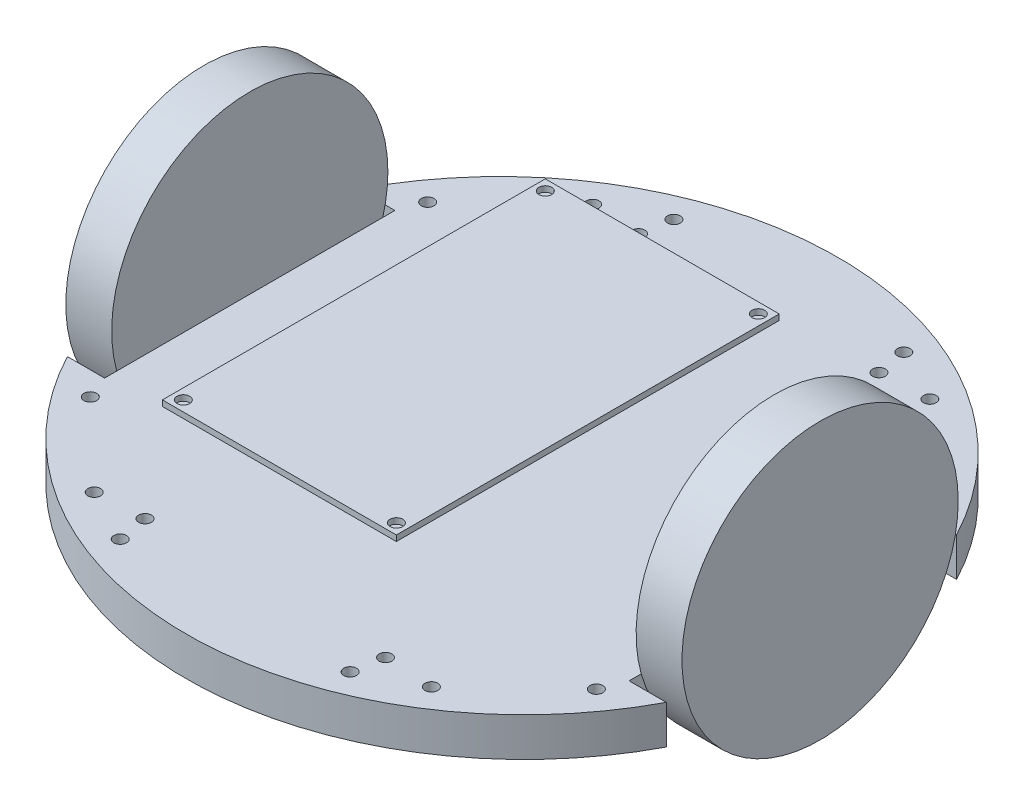
from build123d import *

# Parameters (mm, degrees)
BOSS_EXTRUDE1_DEPTH     = 9.652
SKETCH4_R               = 1.5875
CUT_EXTRUDE1_DEPTH      = 9.652
MIRROR3_COPY_1_SKETCH_R = 1.5875
MIRROR3_COPY_1_DEPTH    = 9.652
SKETCH6_R               = 34.417
BOSS_EXTRUDE2_DEPTH     = 11.43
SKETCH7_W               = 58.293
SKETCH7_H               = 95.4024
BOSS_EXTRUDE3_DEPTH     = 1.4224
SKETCH8_R               = 1.5875
CUT_EXTRUDE2_DEPTH      = 1.4224


with BuildPart() as part:
    # Sketch2 → Boss-Extrude1 (new body)
    with BuildSketch(Plane(origin=(0, 0, 0), x_dir=(1, 0, 0), z_dir=(0, 1, 0))):
        with BuildLine():
            Line((9.271, 72.3392), (74.6125, 72.3392))
            Line((74.6125, 72.3392), (74.6125, 117.4242))
            ThreePointArc((74.6125, 117.4242), (31.024421408, 105.277683937), (0, 72.3392))
            Line((0, 72.3392), (9.271, 72.3392))
        make_face()
        with BuildLine():
            Line((74.6125, 117.4242), (74.6125, 72.3392))
            Line((74.6125, 72.3392), (139.954, 72.3392))
            Line((139.954, 72.3392), (149.225, 72.3392))
            ThreePointArc((149.225, 72.3392), (118.200578592, 105.277683937), (74.6125, 117.4242))
        make_face()
        with BuildLine():
            Line((9.271, 72.3392), (74.6125, 72.3392))
            Line((74.6125, 72.3392), (74.6125, 117.4242))
            ThreePointArc((74.6125, 117.4242), (31.024421408, 105.277683937), (0, 72.3392))
            Line((0, 72.3392), (9.271, 72.3392))
        make_face()
        with BuildLine():
            Line((74.6125, 117.4242), (74.6125, 72.3392))
            Line((74.6125, 72.3392), (139.954, 72.3392))
            Line((139.954, 72.3392), (149.225, 72.3392))
            ThreePointArc((149.225, 72.3392), (118.200578592, 105.277683937), (74.6125, 117.4242))
        make_face()
        Polygon((139.954, 72.3392), (74.6125, 72.3392), (9.271, 72.3392), (9.271, 0), (139.954, 0), align=None)
    boss_extrude1 = extrude(amount=BOSS_EXTRUDE1_DEPTH)

    # Sketch4 → Cut-Extrude1 (cut)
    with BuildSketch(Plane.XZ):
        with Locations((116.619694804, -98.270301239)):
            Circle(SKETCH4_R)
        with Locations((137.668, -78.200678986)):
            Circle(SKETCH4_R)
        with Locations((103.252292028, -105.15636668)):
            Circle(SKETCH4_R)
        with Locations((104.570585987, -97.651268344)):
            Circle(SKETCH4_R)
    cut_extrude1 = extrude(amount=-CUT_EXTRUDE1_DEPTH, mode=Mode.SUBTRACT)

    # Mirror1: Boss-Extrude1 across plane
    add(boss_extrude1.mirror(Plane.XY.offset(-36.1696)))

    # Mirror2: Cut-Extrude1 across plane
    add(cut_extrude1.mirror(Plane(origin=(74.6125, 0, 0), x_dir=(0, 0, 1), z_dir=(1, 0, 0))), mode=Mode.SUBTRACT)

    # Mirror3: Cut-Extrude1 across plane
    add(cut_extrude1.mirror(Plane.XY.offset(-36.1696)), mode=Mode.SUBTRACT)

    # Mirror3 copy 1 sketch → Mirror3 copy 1 (cut)
    with BuildSketch(Plane(origin=(149.225, 0, -72.3392), x_dir=(-1, 0, 0), z_dir=(0, -1, 0))):
        with Locations((116.619694804, -98.270301239)):
            Circle(MIRROR3_COPY_1_SKETCH_R)
        with Locations((137.668, -78.200678986)):
            Circle(MIRROR3_COPY_1_SKETCH_R)
        with Locations((103.252292028, -105.15636668)):
            Circle(MIRROR3_COPY_1_SKETCH_R)
        with Locations((104.570585987, -97.651268344)):
            Circle(MIRROR3_COPY_1_SKETCH_R)
    extrude(amount=-MIRROR3_COPY_1_DEPTH, mode=Mode.SUBTRACT)

    # Sketch6 → Boss-Extrude2 (add)
    with BuildSketch(Plane(origin=(139.954, 0, 0), x_dir=(0, 0, -1), z_dir=(1, 0, 0))):
        with Locations((36.1696, 18.923)):
            Circle(SKETCH6_R)
    boss_extrude2 = extrude(amount=BOSS_EXTRUDE2_DEPTH)

    # Mirror4: Boss-Extrude2 across plane
    add(boss_extrude2.mirror(Plane(origin=(74.6125, 0, 0), x_dir=(0, 0, 1), z_dir=(1, 0, 0))))


with BuildPart() as body_2:
    # Sketch7 → Boss-Extrude3 (new body)
    with BuildSketch(Plane(origin=(0, 32.512, 0), x_dir=(1, 0, 0), z_dir=(0, 1, 0))):
        with Locations((74.6125, 25.908)):
            Rectangle(SKETCH7_W, SKETCH7_H)
    extrude(amount=BOSS_EXTRUDE3_DEPTH)

    # Sketch8 → Cut-Extrude2 (cut)
    with BuildSketch(Plane(origin=(0, 33.9344, 0), x_dir=(1, 0, 0), z_dir=(0, 1, 0))):
        with Locations((101.1555, -19.1897)):
            Circle(SKETCH8_R)
        with Locations((48.0695, -19.1897)):
            Circle(SKETCH8_R)
        with Locations((101.1555, 71.0057)):
            Circle(SKETCH8_R)
        with Locations((48.0695, 71.0057)):
            Circle(SKETCH8_R)
    extrude(amount=-CUT_EXTRUDE2_DEPTH, mode=Mode.SUBTRACT)


solid = Compound([part.part, body_2.part])
